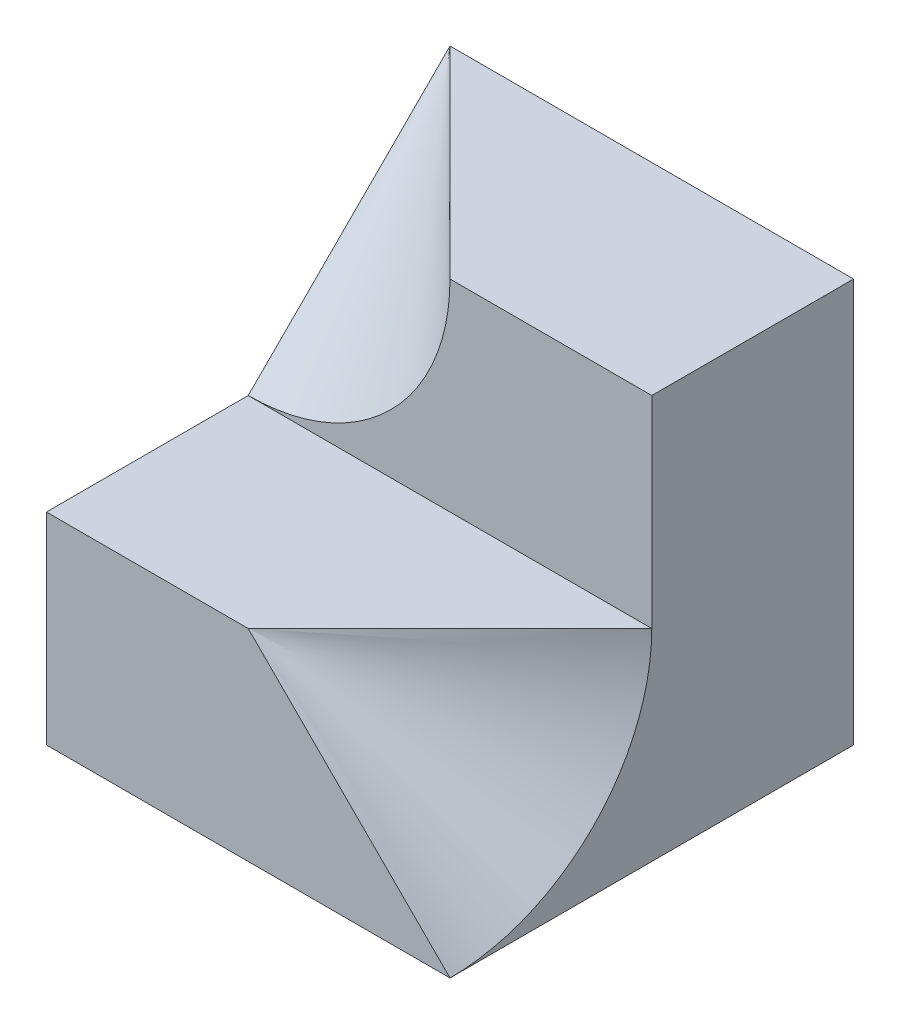
from build123d import *

# Parameters (mm, degrees)
SKETCH1_W           = 4
SKETCH1_H           = 4
BOSS_EXTRUDE1_DEPTH = 4
SKETCH2_W           = 2
SKETCH2_H           = 2
CUT_EXTRUDE1_DEPTH  = 4


with BuildPart() as part:
    # Sketch1 → Boss-Extrude1 (new body)
    with BuildSketch(Plane(origin=(0, 0, 0), x_dir=(1, 0, 0), z_dir=(0, 1, 0))):
        with Locations((2, 2)):
            Rectangle(SKETCH1_W, SKETCH1_H)
    extrude(amount=BOSS_EXTRUDE1_DEPTH)

    # Sketch2 → Cut-Extrude1 (cut)
    with BuildSketch(Plane.ZY):
        with Locations((-1, 3)):
            Rectangle(SKETCH2_W, SKETCH2_H)
    extrude(amount=-CUT_EXTRUDE1_DEPTH, mode=Mode.SUBTRACT)

    # Sketch3 → Cut-Revolve1 (revolve, cut)
    with BuildSketch(Plane.ZY):
        Polygon((-2, 2), (-4, 4), (-2, 4), align=None)
    revolve(axis=Axis((0, 4, -4), (0, 0, 1)), mode=Mode.SUBTRACT)

    # Sketch4 → Cut-Revolve2 (revolve, cut)
    with BuildSketch(Plane.XY):
        Polygon((2, 2), (4, 0), (4, 2), align=None)
    revolve(axis=Axis((4, 2, 0), (-1, 0, 0)), mode=Mode.SUBTRACT)


solid = part.part
